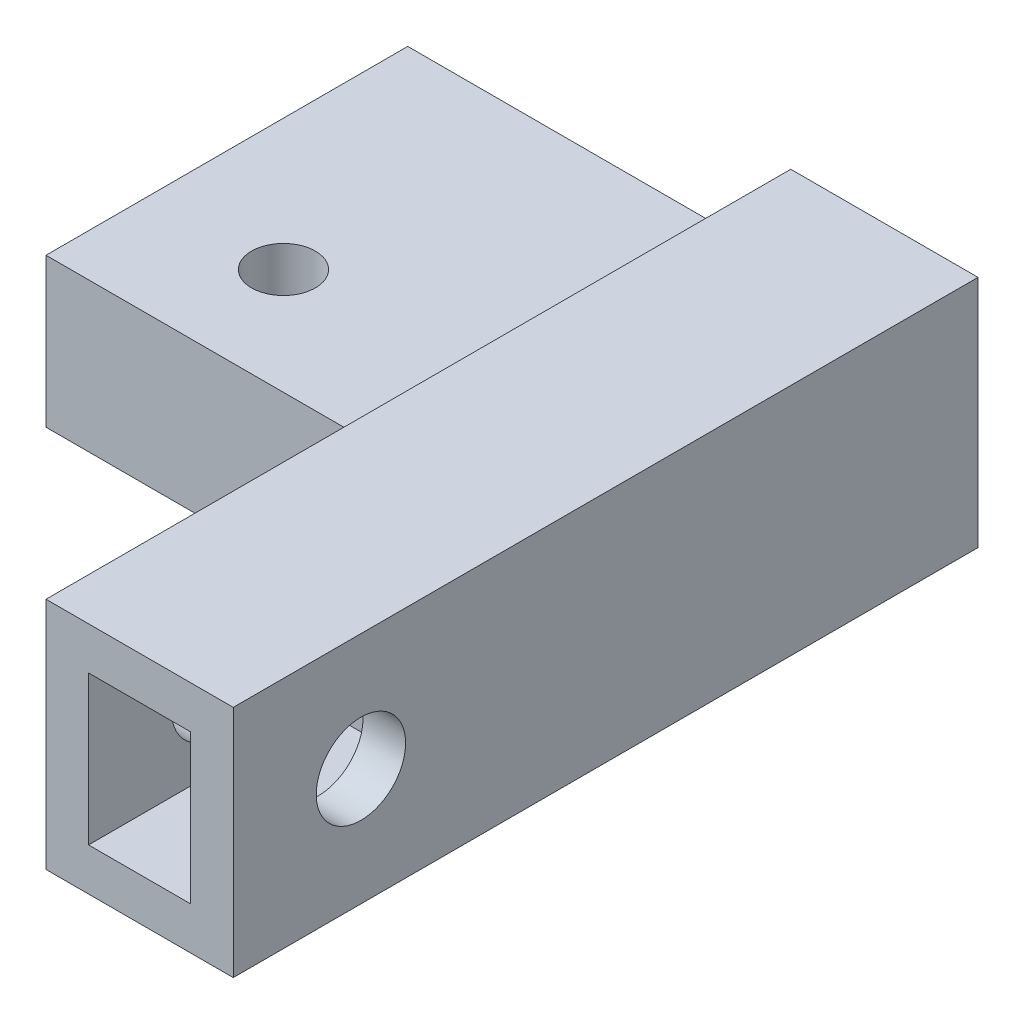
from build123d import *

# Parameters (mm, degrees)
SKETCH_1_W          = 8.8
SKETCH_1_H          = 11
EXTRUDE_1_DEPTH     = 35
SKETCH_2_W          = 4.8
SKETCH_2_H          = 7
CUT_EXTRUDE_1_DEPTH = 11
SKETCH_3_R          = 2.1
CUT_EXTRUDE_2_DEPTH = 11
SKETCH_4_W          = 17
SKETCH_4_H          = 7
EXTRUDE_2_DEPTH     = 18
SKETCH_5_R          = 1.5
CUT_EXTRUDE_3_DEPTH = 4.5


with BuildPart() as part:
    # 草图1 → 凸台-拉伸1 (new body)
    with BuildSketch(Plane.XY):
        Rectangle(SKETCH_1_W, SKETCH_1_H)
    extrude(amount=-EXTRUDE_1_DEPTH)

    # 草图2 → 切除-拉伸1 (cut)
    with BuildSketch(Plane.XY):
        Rectangle(SKETCH_2_W, SKETCH_2_H)
    extrude(amount=-CUT_EXTRUDE_1_DEPTH, mode=Mode.SUBTRACT)

    # 草图3 → 切除-拉伸2 (cut)
    with BuildSketch(Plane.ZY.offset(4.4)):
        with Locations((-6, 0)):
            Circle(SKETCH_3_R)
    extrude(amount=-CUT_EXTRUDE_2_DEPTH, mode=Mode.SUBTRACT)

    # 草图4 → 凸台-拉伸2 (add)
    with BuildSketch(Plane.ZY.offset(4.4)):
        with Locations((-26.5, -2)):
            Rectangle(SKETCH_4_W, SKETCH_4_H)
    extrude(amount=EXTRUDE_2_DEPTH)

    # 草图5 → 切除-拉伸3 (cut)
    with BuildSketch(Plane(origin=(0, 1.5, 0), x_dir=(1, 0, 0), z_dir=(0, 1, 0))):
        with Locations((-16.24, 23)):
            Circle(SKETCH_5_R)
    extrude(amount=-CUT_EXTRUDE_3_DEPTH, mode=Mode.SUBTRACT)


solid = part.part
